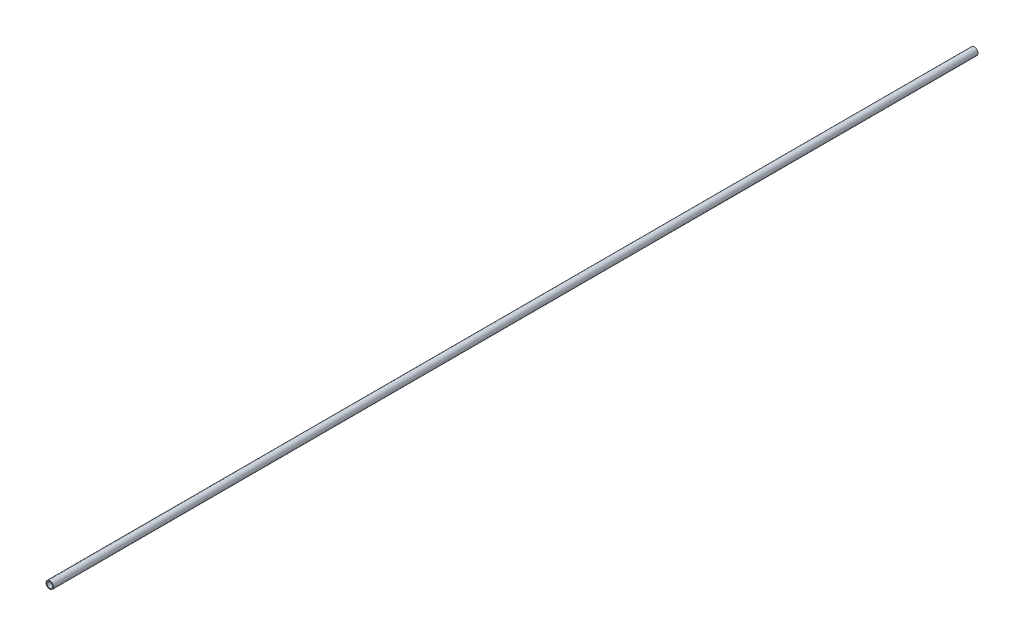
from build123d import *

# Parameters (mm, degrees)
ESBO_O1_R                = 4
ESBO_O1_R_2              = 3
RESSALTO_EXTRUS_O1_DEPTH = 1000


with BuildPart() as part:
    # Esboço1 → Ressalto-extrusão1 (new body)
    with BuildSketch(Plane.XY):
        Circle(ESBO_O1_R)
        Circle(ESBO_O1_R_2, mode=Mode.SUBTRACT)
    extrude(amount=RESSALTO_EXTRUS_O1_DEPTH)


solid = part.part
